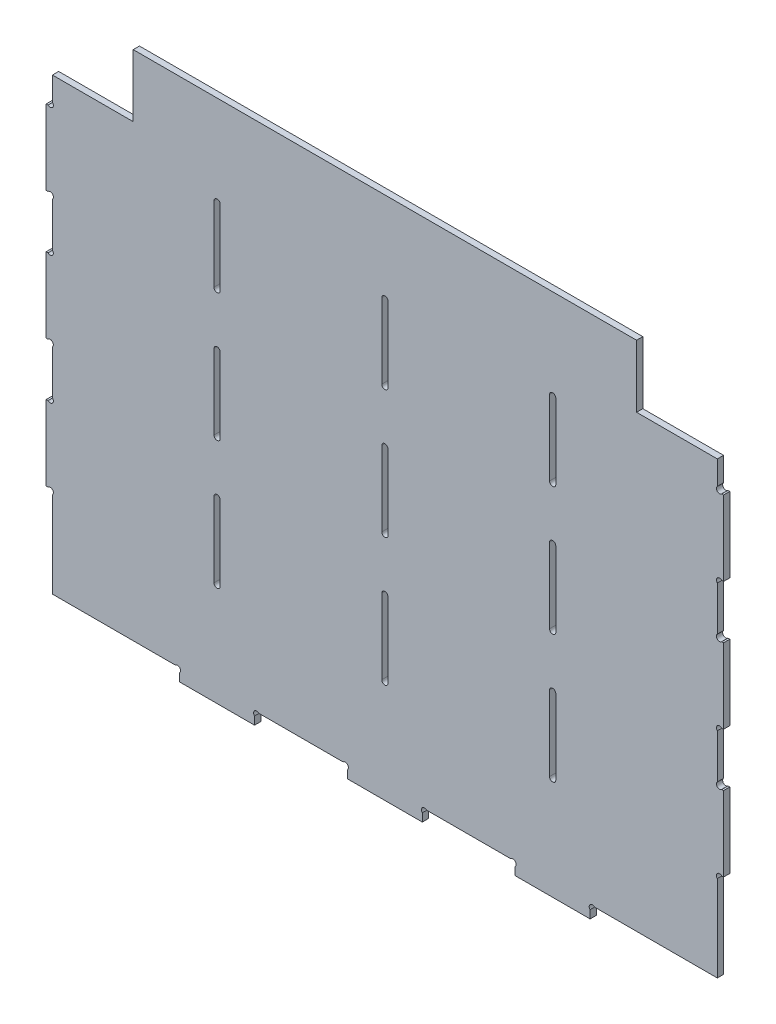
from build123d import *

# Parameters (mm, degrees)
SKETCH1_W           = 338.325
SKETCH1_H           = 260.5
BOSS_EXTRUDE1_DEPTH = 1.5875
CUT_EXTRUDE1_DEPTH  = 3.175
SKETCH4_W           = 3.175
SKETCH4_H           = 38.1
SKETCH4_W_2         = 38.1
SKETCH4_H_2         = 6.35
BOSS_EXTRUDE2_DEPTH = 3.175
SKETCH5_R           = 1.5875
CUT_EXTRUDE3_DEPTH  = 3.175
SKETCH6_W           = 42.6875
SKETCH6_H           = 31.75
CUT_EXTRUDE4_DEPTH  = 3.175


with BuildPart() as part:
    # Sketch1 → Boss-Extrude1 (new body, symmetric)
    with BuildSketch(Plane.XY):
        with Locations((170.75, 133.425)):
            Rectangle(SKETCH1_W, SKETCH1_H)
    extrude(amount=BOSS_EXTRUDE1_DEPTH, both=True)

    # Sketch3 → Cut-Extrude1 (cut)
    with BuildSketch(Plane.XY.offset(1.5875)):
        with BuildLine():
            Line((169.1625, 217.6), (169.1625, 179.5))
            ThreePointArc((169.1625, 179.5), (170.75, 177.9125), (172.3375, 179.5))
            Line((172.3375, 179.5), (172.3375, 217.6))
            ThreePointArc((172.3375, 217.6), (170.75, 219.1875), (169.1625, 217.6))
        make_face()
        with BuildLine():
            Line((83.7875, 217.6), (83.7875, 179.5))
            ThreePointArc((83.7875, 179.5), (85.375, 177.9125), (86.9625, 179.5))
            Line((86.9625, 179.5), (86.9625, 217.6))
            ThreePointArc((86.9625, 217.6), (85.375, 219.1875), (83.7875, 217.6))
        make_face()
        with BuildLine():
            Line((254.5375, 217.6), (254.5375, 179.5))
            ThreePointArc((254.5375, 179.5), (256.125, 177.9125), (257.7125, 179.5))
            Line((257.7125, 179.5), (257.7125, 217.6))
            ThreePointArc((257.7125, 217.6), (256.125, 219.1875), (254.5375, 217.6))
        make_face()
        with BuildLine():
            Line((169.1625, 152.475), (169.1625, 114.375))
            ThreePointArc((169.1625, 114.375), (170.75, 112.7875), (172.3375, 114.375))
            Line((172.3375, 114.375), (172.3375, 152.475))
            ThreePointArc((172.3375, 152.475), (170.75, 154.0625), (169.1625, 152.475))
        make_face()
        with BuildLine():
            Line((83.7875, 152.475), (83.7875, 114.375))
            ThreePointArc((83.7875, 114.375), (85.375, 112.7875), (86.9625, 114.375))
            Line((86.9625, 114.375), (86.9625, 152.475))
            ThreePointArc((86.9625, 152.475), (85.375, 154.0625), (83.7875, 152.475))
        make_face()
        with BuildLine():
            Line((254.5375, 152.475), (254.5375, 114.375))
            ThreePointArc((254.5375, 114.375), (256.125, 112.7875), (257.7125, 114.375))
            Line((257.7125, 114.375), (257.7125, 152.475))
            ThreePointArc((257.7125, 152.475), (256.125, 154.0625), (254.5375, 152.475))
        make_face()
        with BuildLine():
            Line((169.1625, 87.35), (169.1625, 49.25))
            ThreePointArc((169.1625, 49.25), (170.75, 47.6625), (172.3375, 49.25))
            Line((172.3375, 49.25), (172.3375, 87.35))
            ThreePointArc((172.3375, 87.35), (170.75, 88.9375), (169.1625, 87.35))
        make_face()
        with BuildLine():
            Line((83.7875, 87.35), (83.7875, 49.25))
            ThreePointArc((83.7875, 49.25), (85.375, 47.6625), (86.9625, 49.25))
            Line((86.9625, 49.25), (86.9625, 87.35))
            ThreePointArc((86.9625, 87.35), (85.375, 88.9375), (83.7875, 87.35))
        make_face()
        with BuildLine():
            Line((254.5375, 87.35), (254.5375, 49.25))
            ThreePointArc((254.5375, 49.25), (256.125, 47.6625), (257.7125, 49.25))
            Line((257.7125, 49.25), (257.7125, 87.35))
            ThreePointArc((257.7125, 87.35), (256.125, 88.9375), (254.5375, 87.35))
        make_face()
    extrude(amount=-CUT_EXTRUDE1_DEPTH, mode=Mode.SUBTRACT)

    # Sketch4 → Boss-Extrude2 (add)
    with BuildSketch(Plane.XY.offset(1.5875)):
        with Locations((0, 198.55)):
            Rectangle(SKETCH4_W, SKETCH4_H)
        with Locations((0, 133.425)):
            Rectangle(SKETCH4_W, SKETCH4_H)
        with Locations((0, 68.3)):
            Rectangle(SKETCH4_W, SKETCH4_H)
        with Locations((85.375, 0)):
            Rectangle(SKETCH4_W_2, SKETCH4_H_2)
        with Locations((170.75, 0)):
            Rectangle(SKETCH4_W_2, SKETCH4_H_2)
        with Locations((256.125, 0)):
            Rectangle(SKETCH4_W_2, SKETCH4_H_2)
        with Locations((341.5, 68.3)):
            Rectangle(SKETCH4_W, SKETCH4_H)
        with Locations((341.5, 133.425)):
            Rectangle(SKETCH4_W, SKETCH4_H)
        with Locations((341.5, 198.55)):
            Rectangle(SKETCH4_W, SKETCH4_H)
    extrude(amount=-BOSS_EXTRUDE2_DEPTH)

    # Sketch5 → Cut-Extrude3 (cut)
    with BuildSketch(Plane.XY.offset(1.5875)):
        with Locations((0.464967985, 218.722532015)):
            Circle(SKETCH5_R)
        with Locations((0.464967985, 178.377467985)):
            Circle(SKETCH5_R)
        with Locations((0.464967985, 153.597532015)):
            Circle(SKETCH5_R)
        with Locations((0.464967985, 113.252467985)):
            Circle(SKETCH5_R)
        with Locations((0.464967985, 88.472532015)):
            Circle(SKETCH5_R)
        with Locations((0.464967985, 48.127467985)):
            Circle(SKETCH5_R)
        with Locations((341.035032015, 48.127467985)):
            Circle(SKETCH5_R)
        with Locations((341.035032015, 88.472532015)):
            Circle(SKETCH5_R)
        with Locations((341.035032015, 113.252467985)):
            Circle(SKETCH5_R)
        with Locations((341.035032015, 153.597532015)):
            Circle(SKETCH5_R)
        with Locations((341.035032015, 178.377467985)):
            Circle(SKETCH5_R)
        with Locations((341.035032015, 218.722532015)):
            Circle(SKETCH5_R)
        with Locations((65.202467985, 2.052467985)):
            Circle(SKETCH5_R)
        with Locations((105.547532015, 2.052467985)):
            Circle(SKETCH5_R)
        with Locations((150.577467985, 2.052467985)):
            Circle(SKETCH5_R)
        with Locations((190.922532015, 2.052467985)):
            Circle(SKETCH5_R)
        with Locations((235.952467985, 2.052467985)):
            Circle(SKETCH5_R)
        with Locations((276.297532015, 2.052467985)):
            Circle(SKETCH5_R)
    extrude(amount=-CUT_EXTRUDE3_DEPTH, mode=Mode.SUBTRACT)

    # Sketch6 → Cut-Extrude4 (cut)
    with BuildSketch(Plane.XY.offset(1.5875)):
        with Locations((320.15625, 247.8)):
            Rectangle(SKETCH6_W, SKETCH6_H)
        with Locations((21.34375, 247.8)):
            Rectangle(SKETCH6_W, SKETCH6_H)
    extrude(amount=-CUT_EXTRUDE4_DEPTH, mode=Mode.SUBTRACT)


solid = part.part
